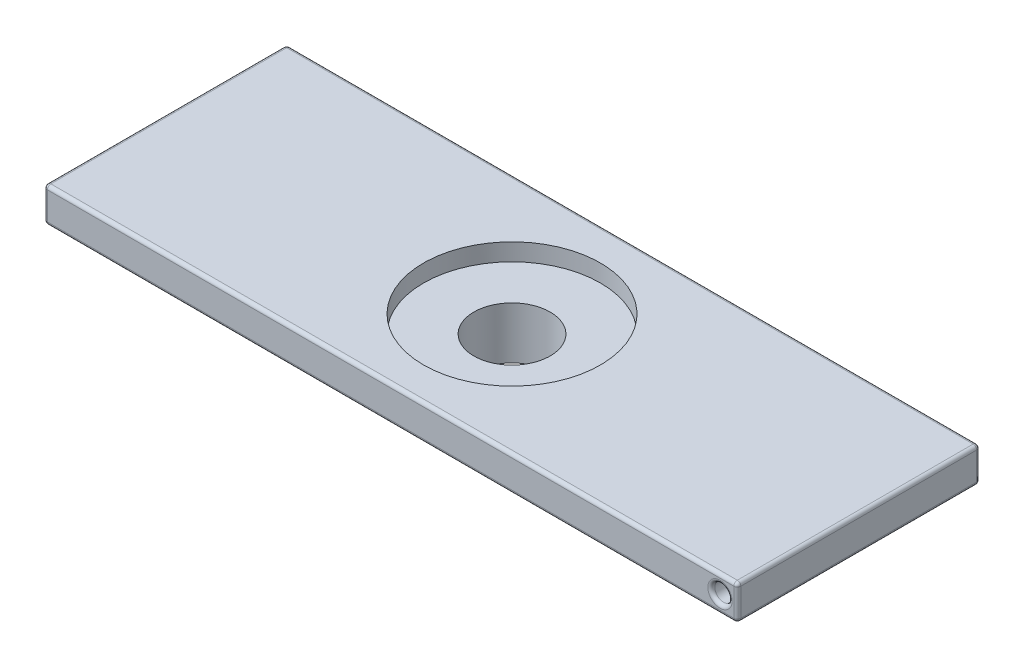
from build123d import *

# Parameters (mm, degrees)
SKETCH1_R           = 12
SKETCH1_R_2         = 11
BOSS_EXTRUDE1_DEPTH = 10
SKETCH2_W           = 200
SKETCH2_H           = 70
BOSS_EXTRUDE2_DEPTH = 10
CUT_EXTRUDE1_REACH  = 12
SKETCH3_R           = 11
SKETCH4_R           = 25.5
CUT_EXTRUDE2_DEPTH  = 5
SKETCH5_R           = 2.5
CUT_EXTRUDE3_DEPTH  = 40
SKETCH6_R           = 2.5
CUT_EXTRUDE4_DEPTH  = 40
FILLET1_R           = 1


with BuildPart() as part:
    # Sketch1 → Boss-Extrude1 (new body)
    with BuildSketch(Plane(origin=(0, 0, 0), x_dir=(1, 0, 0), z_dir=(0, 1, 0))):
        with Locations(Location((0, 0, 0), (0, 0, 270))):  # turned: the seam where the file's is
            Circle(SKETCH1_R)
        with Locations(Location((0, 0, 0), (0, 0, 270))):  # turned: the seam where the file's is
            Circle(SKETCH1_R_2, mode=Mode.SUBTRACT)
    extrude(amount=BOSS_EXTRUDE1_DEPTH)

    # Sketch2 → Boss-Extrude2 (add)
    with BuildSketch(Plane(origin=(0, 10, 0), x_dir=(1, 0, 0), z_dir=(0, 1, 0))):
        Rectangle(SKETCH2_W, SKETCH2_H)
    extrude(amount=BOSS_EXTRUDE2_DEPTH)

    # Sketch3 → Cut-Extrude1 (cut, up to next)
    with BuildSketch(Plane.XZ.offset(-10), mode=Mode.PRIVATE) as cut_extrude1_sk1:
        with Locations(Location((0, 0, 0), (0, 0, 270))):  # turned: the seam where the file's is
            Circle(SKETCH3_R)
    cut_extrude1_tool1 = extrude(cut_extrude1_sk1.sketch, amount=-CUT_EXTRUDE1_REACH, mode=Mode.PRIVATE) & part.part
    add(cut_extrude1_tool1.solids().sort_by_distance((0, 10, 0))[0], mode=Mode.SUBTRACT)

    # Sketch4 → Cut-Extrude2 (cut)
    with BuildSketch(Plane(origin=(0, 20, 0), x_dir=(1, 0, 0), z_dir=(0, 1, 0))):
        with Locations(Location((0, 0, 0), (0, 0, 270))):  # turned: the seam where the file's is
            Circle(SKETCH4_R)
    extrude(amount=-CUT_EXTRUDE2_DEPTH, mode=Mode.SUBTRACT)

    # Sketch5 → Cut-Extrude3 (cut)
    with BuildSketch(Plane.XY.offset(35)):
        with Locations((95, 15)):
            Circle(SKETCH5_R)
    extrude(amount=-CUT_EXTRUDE3_DEPTH, mode=Mode.SUBTRACT)

    # Sketch6 → Cut-Extrude4 (cut)
    with BuildSketch(Plane(origin=(0, 0, -35), x_dir=(-1, 0, 0), z_dir=(0, 0, -1))):
        with Locations((95, 15)):
            Circle(SKETCH6_R)
    extrude(amount=-CUT_EXTRUDE4_DEPTH, mode=Mode.SUBTRACT)

    # Fillet1
    fillet1_edges = [part.edges().sort_by_distance(p)[0] for p in [
        (100, 10, 0),
        (100, 15, 35),
        (0, 10, -35),
        (100, 15, -35),
        (-100, 10, 0),
        (-100, 15, -35),
        (0, 10, 35),
        (-100, 15, 35),
        (100, 20, 0),
        (0, 20, -35),
        (-100, 20, 0),
        (0, 20, 35),
        (92.5, 15, 35),
        (-92.5, 15, -35),
    ]]
    fillet(fillet1_edges, radius=FILLET1_R)


solid = part.part
